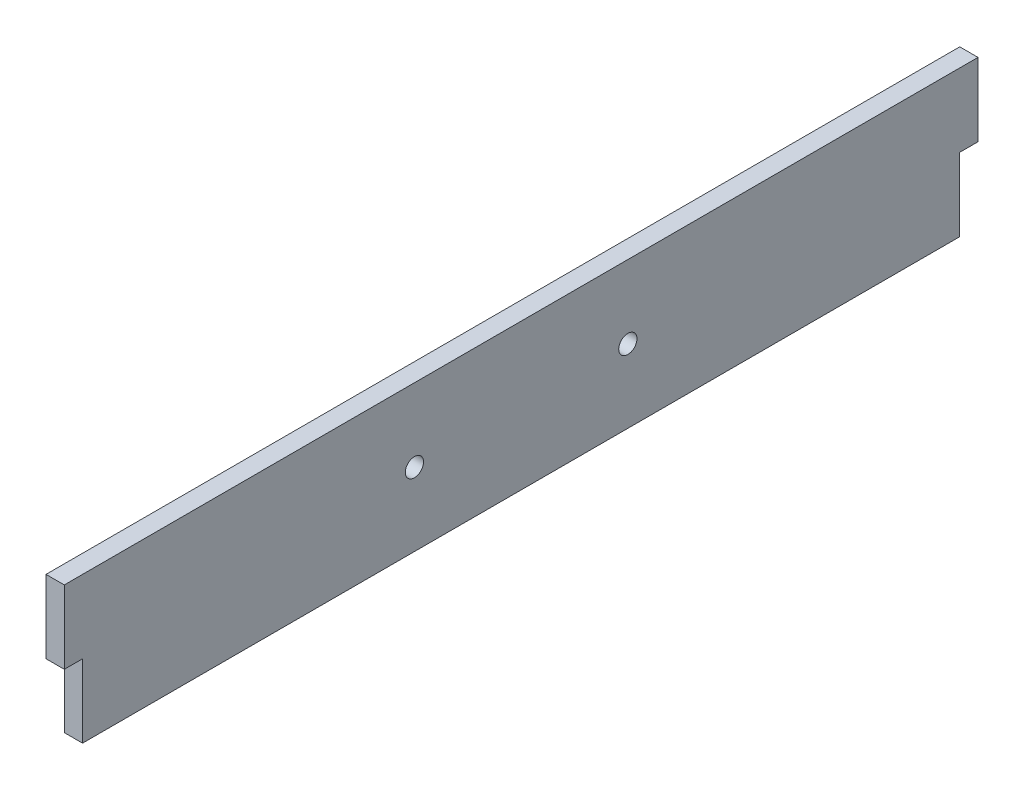
from build123d import *

# Parameters (mm, degrees)
SKETCH1_W           = 158.75
SKETCH1_H           = 25.4
BOSS_EXTRUDE1_DEPTH = 3.175
SKETCH2_R           = 1.5875
SKETCH2_W           = 3.175
SKETCH2_H           = 12.7
CUT_EXTRUDE1_DEPTH  = 4.175


with BuildPart() as part:
    # Sketch1 → Boss-Extrude1 (new body)
    with BuildSketch(Plane(origin=(0, 0, 0), x_dir=(0, 0, -1), z_dir=(1, 0, 0))):
        with Locations((79.375, 12.7)):
            Rectangle(SKETCH1_W, SKETCH1_H)
    extrude(amount=BOSS_EXTRUDE1_DEPTH)

    # Sketch2 → Cut-Extrude1 (cut, through all)
    with BuildSketch(Plane.ZY):
        with Locations((-97.917, 12.7)):
            Circle(SKETCH2_R)
        with Locations((-60.833, 12.7)):
            Circle(SKETCH2_R)
        with Locations((-1.5875, 6.35)):
            Rectangle(SKETCH2_W, SKETCH2_H)
        with Locations((-157.1625, 6.35)):
            Rectangle(SKETCH2_W, SKETCH2_H)
    extrude(amount=-CUT_EXTRUDE1_DEPTH, mode=Mode.SUBTRACT)


solid = part.part
